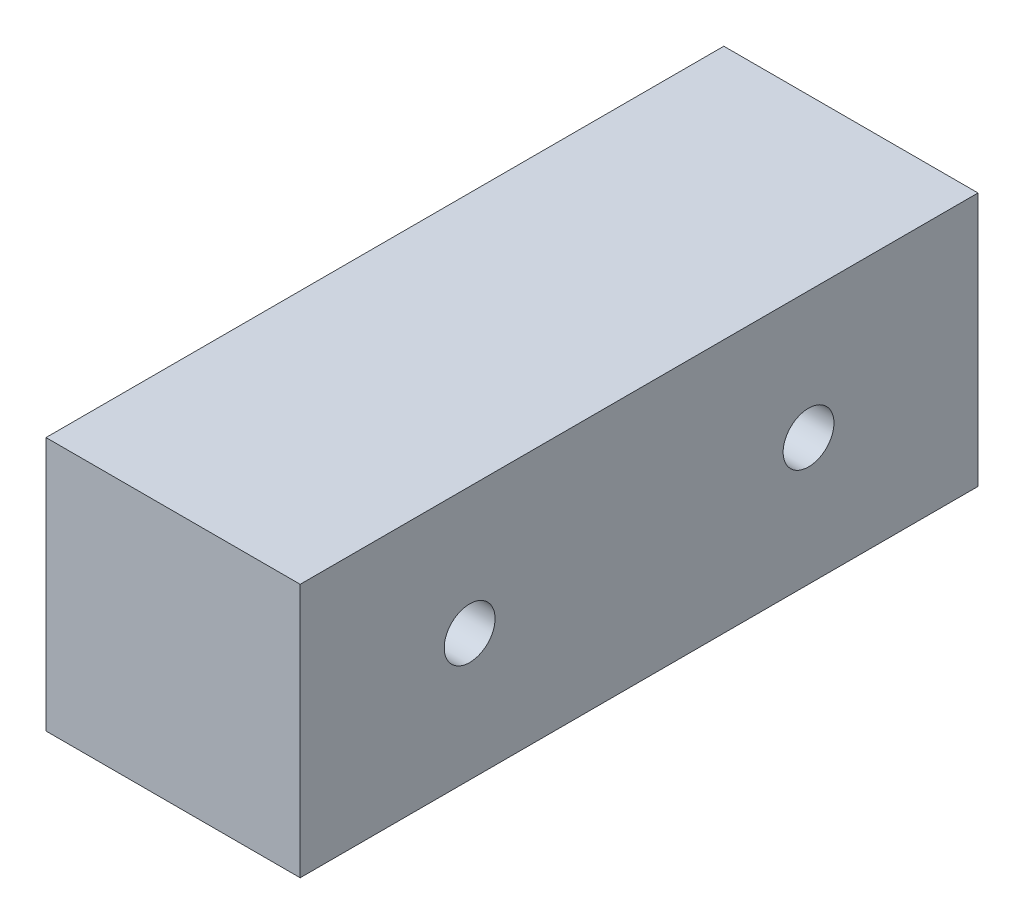
from build123d import *

# Parameters (mm, degrees)
SKETCH1_W           = 150
SKETCH1_H           = 400
BOSS_EXTRUDE1_DEPTH = 150
SKETCH2_R           = 15
CUT_EXTRUDE1_DEPTH  = 151


with BuildPart() as part:
    # Sketch1 → Boss-Extrude1 (new body)
    with BuildSketch(Plane(origin=(0, 0, 0), x_dir=(1, 0, 0), z_dir=(0, 1, 0))):
        with Locations((75, 200)):
            Rectangle(SKETCH1_W, SKETCH1_H)
    extrude(amount=BOSS_EXTRUDE1_DEPTH)

    # Sketch2 → Cut-Extrude1 (cut, through all)
    with BuildSketch(Plane(origin=(150, 0, 0), x_dir=(0, 0, -1), z_dir=(1, 0, 0))):
        with Locations((300, 75)):
            Circle(SKETCH2_R)
        with Locations((100, 75)):
            Circle(SKETCH2_R)
    extrude(amount=-CUT_EXTRUDE1_DEPTH, mode=Mode.SUBTRACT)


solid = part.part
